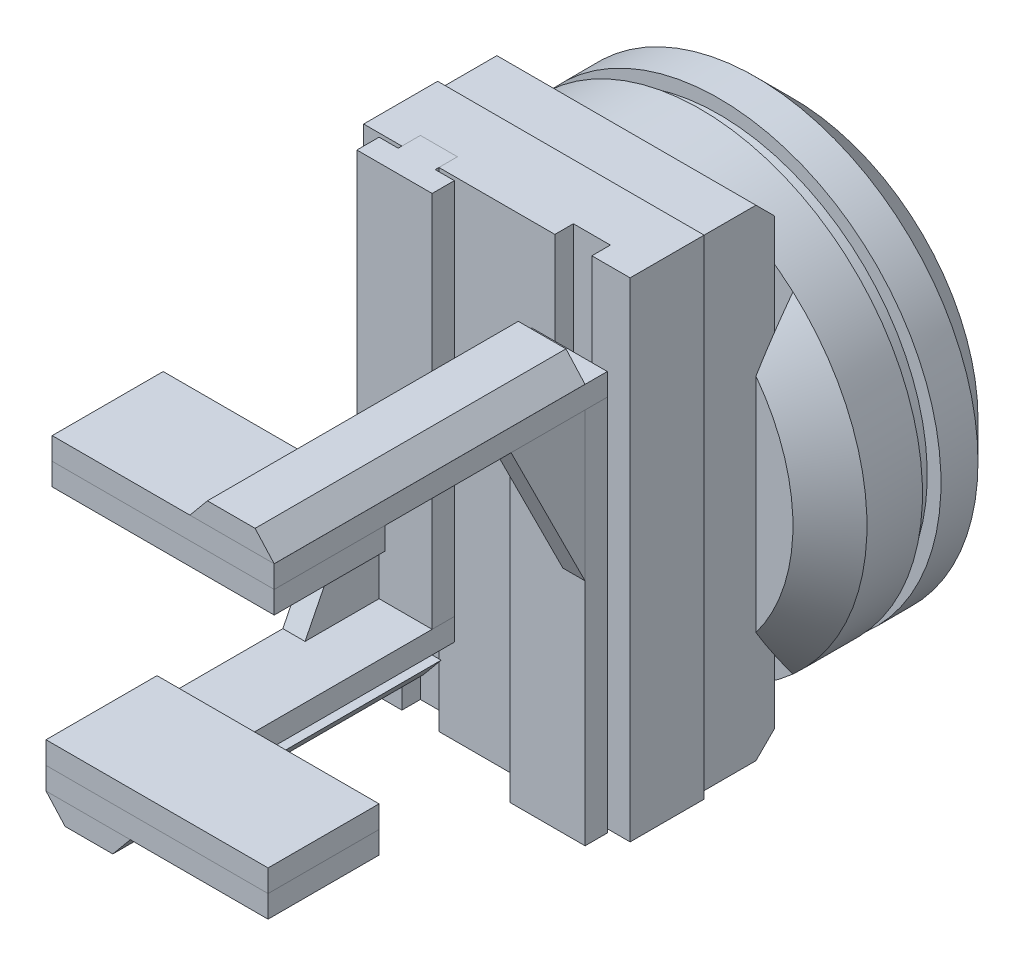
from build123d import *

# Parameters (mm, degrees)
SKETCH1_R            = 60
BOSS_EXTRUDE1_DEPTH  = 50
SKETCH2_W            = 80
SKETCH2_H            = 439.775188774
CUT_EXTRUDE1_DEPTH   = 10
SKETCH3_W            = 70
SKETCH3_H            = 130
BOSS_EXTRUDE2_DEPTH  = 20
SKETCH4_W            = 72
SKETCH4_H            = 132
BOSS_EXTRUDE3_DEPTH  = 20
SKETCH5_W            = 10
SKETCH5_H            = 10
CUT_EXTRUDE2_DEPTH   = 133
SKETCH6_W            = 10
SKETCH6_H            = 102
BOSS_EXTRUDE4_DEPTH  = 6
SKETCH7_W            = 20.334631896
SKETCH7_H            = 102
BOSS_EXTRUDE5_DEPTH  = 6
BOSS_EXTRUDE6_DEPTH  = 6
SKETCH10_W           = 60
SKETCH10_H           = 30
BOSS_EXTRUDE7_DEPTH  = 6
BOSS_EXTRUDE8_DEPTH  = 6
BOSS_EXTRUDE9_DEPTH  = 84
CIRPATTERN1_COUNT    = 2
CUT_EXTRUDE3_START   = -20
SKETCH13_R           = 60
SKETCH13_R_2         = 56.287813336
CUT_EXTRUDE3_DEPTH   = 5
CHAMFER1_SIZE        = 10
SKETCH14_R           = 30
CUT_EXTRUDE4_DEPTH   = 5
SKETCH15_R           = 35
SKETCH15_R_2         = 30
BOSS_EXTRUDE10_DEPTH = 5
CHAMFER2_SIZE        = 10
CHAMFER3_SIZE        = 10
CHAMFER4_SIZE        = 5


with BuildPart() as part:
    # Sketch1 → Boss-Extrude1 (new body)
    with BuildSketch(Plane.XY):
        Circle(SKETCH1_R)
    extrude(amount=BOSS_EXTRUDE1_DEPTH)

    # Sketch2 → Cut-Extrude1 (cut)
    with BuildSketch(Plane.XY.offset(50)):
        Rectangle(SKETCH2_W, SKETCH2_H)
    extrude(amount=-CUT_EXTRUDE1_DEPTH, mode=Mode.SUBTRACT)

    # Sketch13 → Cut-Extrude3 (cut)
    with BuildSketch(Plane(origin=(0, 0, 0), x_dir=(-1, 0, 0), z_dir=(0, 0, -1)).offset(CUT_EXTRUDE3_START)):
        Circle(SKETCH13_R)
        Circle(SKETCH13_R_2, mode=Mode.SUBTRACT)
    extrude(amount=-CUT_EXTRUDE3_DEPTH, mode=Mode.SUBTRACT)

    # Chamfer1
    chamfer1_edges = [part.edges().sort_by_distance(p)[0] for p in [
        (-60, 0, 0),
    ]]
    chamfer(chamfer1_edges, length=CHAMFER1_SIZE)

    # Sketch14 → Cut-Extrude4 (cut)
    with BuildSketch(Plane(origin=(0, 0, 0), x_dir=(-1, 0, 0), z_dir=(0, 0, -1))):
        Circle(SKETCH14_R)
    extrude(amount=-CUT_EXTRUDE4_DEPTH, mode=Mode.SUBTRACT)

    # Chamfer2
    chamfer2_edges = [part.edges().sort_by_distance(p)[0] for p in [
        (54.772255751, 24.494897428, 50),
    ]]
    chamfer(chamfer2_edges, length=CHAMFER2_SIZE)

    # Chamfer3
    chamfer3_edges = [part.edges().sort_by_distance(p)[0] for p in [
        (-60, 0, 50),
    ]]
    chamfer(chamfer3_edges, length=CHAMFER3_SIZE)


with BuildPart() as body_2:
    # Sketch3 → Boss-Extrude2 (new body)
    with BuildSketch(Plane.XY.offset(40)):
        Rectangle(SKETCH3_W, SKETCH3_H)
    extrude(amount=BOSS_EXTRUDE2_DEPTH)

    # Chamfer4
    chamfer4_edges = [body_2.edges().sort_by_distance(p)[0] for p in [
        (0, -65, 40),
        (0, 65, 40),
    ]]
    chamfer(chamfer4_edges, length=CHAMFER4_SIZE)


with BuildPart() as body_3:
    # Sketch4 → Boss-Extrude3 (new body)
    with BuildSketch(Plane.XY.offset(60)):
        Rectangle(SKETCH4_W, SKETCH4_H)
    extrude(amount=BOSS_EXTRUDE3_DEPTH)

    # Sketch5 → Cut-Extrude2 (cut, through all)
    with BuildSketch(Plane.XZ.offset(66)):
        with Locations((-20.665368104, 80)):
            Rectangle(SKETCH5_W, SKETCH5_H)
        with Locations((20.665368104, 80)):
            Rectangle(SKETCH5_W, SKETCH5_H)
    extrude(amount=-CUT_EXTRUDE2_DEPTH, mode=Mode.SUBTRACT)


with BuildPart() as body_4:
    # Sketch6 → Boss-Extrude4 (new body)
    with BuildSketch(Plane.XY.offset(75)):
        with Locations((20.665368104, -15)):
            Rectangle(SKETCH6_W, SKETCH6_H)
    extrude(amount=BOSS_EXTRUDE4_DEPTH)

    # Sketch7 → Boss-Extrude5 (add)
    with BuildSketch(Plane.XY.offset(81)):
        with Locations((20.665368104, -15)):
            Rectangle(SKETCH7_W, SKETCH7_H)
    extrude(amount=BOSS_EXTRUDE5_DEPTH)


with BuildPart() as body_5:
    # Sketch9 → Boss-Extrude6 (new body)
    with BuildSketch(Plane(origin=(0, 36, 0), x_dir=(1, 0, 0), z_dir=(0, 1, 0))):
        Polygon((30.832684052, -81), (30.832684052, -171), (-29.167315948, -171), (-29.167315948, -141), (10.498052156, -141), (10.498052156, -81), align=None)
    extrude(amount=BOSS_EXTRUDE6_DEPTH)


with BuildPart() as body_6:
    # Sketch10 → Boss-Extrude7 (new body)
    with BuildSketch(Plane.XZ.offset(-36)):
        with Locations((0.832684052, 156)):
            Rectangle(SKETCH10_W, SKETCH10_H)
    extrude(amount=BOSS_EXTRUDE7_DEPTH)


with BuildPart() as body_7:
    # Sketch11 → Boss-Extrude8 (new body)
    with BuildSketch(Plane(origin=(30.832684052, 0, 0), x_dir=(0, 0, -1), z_dir=(1, 0, 0))):
        Polygon((-107, 36), (-87, -4), (-87, 36), align=None)
    extrude(amount=-BOSS_EXTRUDE8_DEPTH)


with BuildPart() as body_8:
    # Sketch12 → Boss-Extrude9 (new body)
    with BuildSketch(Plane.XY.offset(171)):
        Polygon((30.818616655, 42), (25.665368104, 47.716299083), (12.782721681, 47.716299083), (8.054865717, 42), align=None)
    extrude(amount=-BOSS_EXTRUDE9_DEPTH)


with BuildPart() as cirpattern1_1:
    # CirPattern1: pattern copy
    add(body_8.part.rotate(Axis((0, 0, 0), (0, 0, 1)), 1 * 360 / CIRPATTERN1_COUNT))


with BuildPart() as cirpattern1_2:
    # CirPattern1: pattern copy
    add(body_4.part.rotate(Axis((0, 0, 0), (0, 0, 1)), 1 * 360 / CIRPATTERN1_COUNT))


with BuildPart() as cirpattern1_3:
    # CirPattern1: pattern copy
    add(body_7.part.rotate(Axis((0, 0, 0), (0, 0, 1)), 1 * 360 / CIRPATTERN1_COUNT))


with BuildPart() as cirpattern1_4:
    # CirPattern1: pattern copy
    add(body_5.part.rotate(Axis((0, 0, 0), (0, 0, 1)), 1 * 360 / CIRPATTERN1_COUNT))


with BuildPart() as cirpattern1_5:
    # CirPattern1: pattern copy
    add(body_6.part.rotate(Axis((0, 0, 0), (0, 0, 1)), 1 * 360 / CIRPATTERN1_COUNT))


with BuildPart() as body_14:
    # Sketch15 → Boss-Extrude10 (new body)
    with BuildSketch(Plane(origin=(0, 0, 0), x_dir=(-1, 0, 0), z_dir=(0, 0, -1))):
        Circle(SKETCH15_R)
        Circle(SKETCH15_R_2, mode=Mode.SUBTRACT)
    extrude(amount=BOSS_EXTRUDE10_DEPTH)


solid = Compound([part.part, body_2.part, body_3.part, body_4.part, body_5.part, body_6.part, body_7.part, body_8.part, cirpattern1_1.part, cirpattern1_2.part, cirpattern1_3.part, cirpattern1_4.part, cirpattern1_5.part, body_14.part])
